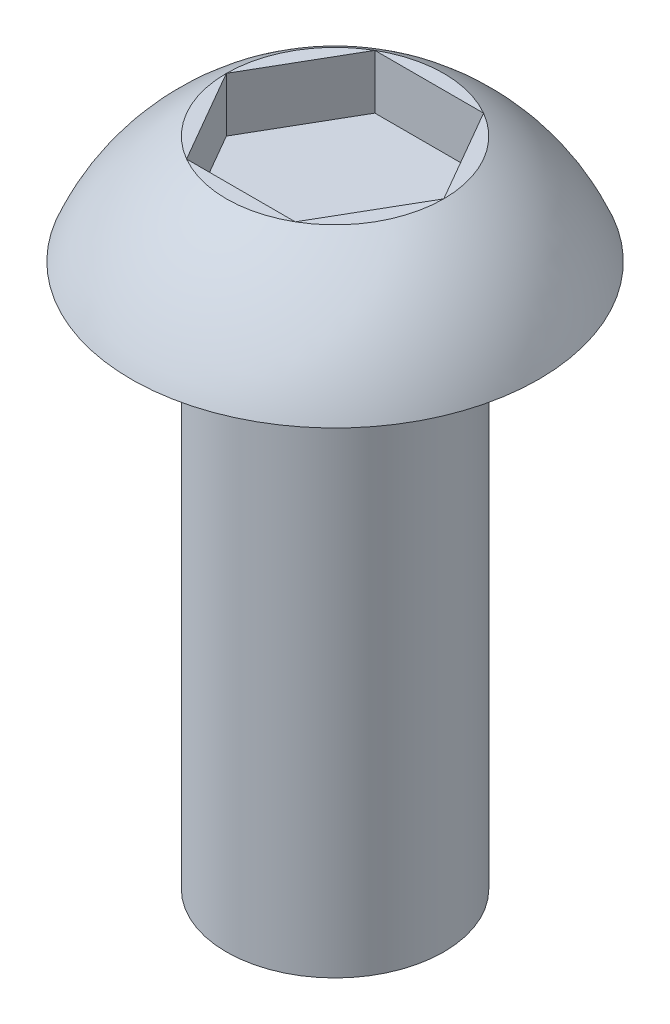
from build123d import *

# Parameters (mm, degrees)
CUT_EXTRUDE1_DEPTH = 1


with BuildPart() as part:
    # Sketch1 → Revolve1 (revolve)
    with BuildSketch(Plane.XY):
        with BuildLine():
            Line((0, 0), (2, 0))
            Line((2, 0), (2, 10))
            Line((2, 10), (3.75, 10))
            ThreePointArc((3.75, 10), (3.043948915, 11.147830301), (2, 12))
            Line((2, 12), (0, 12))
            Line((0, 12), (0, 0))
        make_face()
    revolve(axis=Axis((0, -310.205901947, 0), (0, 1, 0)))

    # Sketch2 → Cut-Extrude1 (cut)
    with BuildSketch(Plane(origin=(0, 12, 0), x_dir=(1, 0, 0), z_dir=(0, 1, 0))):
        Polygon((2, 0), (1, 1.732050808), (-1, 1.732050808), (-2, 0), (-1, -1.732050808), (1, -1.732050808), align=None)
    extrude(amount=-CUT_EXTRUDE1_DEPTH, mode=Mode.SUBTRACT)


solid = part.part
